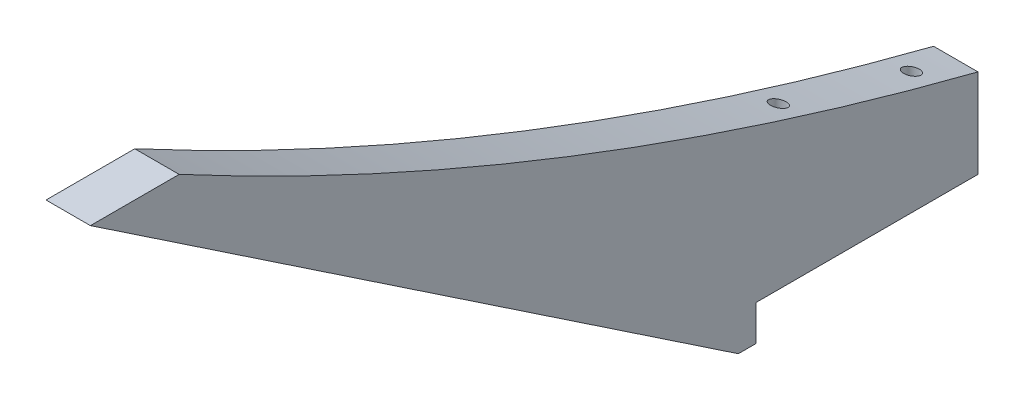
from build123d import *

# Parameters (mm, degrees)
BOSS_EXTRUDE1_DEPTH   = 6.35
F_4_40_TAPPED_HOLE1_D = 2.2606


with BuildPart() as part:
    # Sketch1 → Boss-Extrude1 (new body)
    with BuildSketch(Plane(origin=(0, 0, 0), x_dir=(0, 0, -1), z_dir=(1, 0, 0))):
        with BuildLine():
            Line((0, 0), (0, 12.7))
            ThreePointArc((0, 12.7), (-58.496284585, 31.463125354), (-114.3, 57.15))
            Line((-114.3, 57.15), (-127, 57.15))
            Line((-127, 57.15), (-34.29, -5.08))
            Line((-34.29, -5.08), (-31.75, -5.08))
            Line((-31.75, -5.08), (-31.75, 0))
            Line((-31.75, 0), (0, 0))
        make_face()
    extrude(amount=BOSS_EXTRUDE1_DEPTH)

    # #4-40 Tapped Hole1 (through all)
    with Locations(Plane(origin=(0, 0, 0), x_dir=(-1, 0, 0), z_dir=(0, -1, 0))):
        with Locations((-3.175, -25.4), (-3.175, -6.35)):
            Hole(F_4_40_TAPPED_HOLE1_D / 2)


solid = part.part
